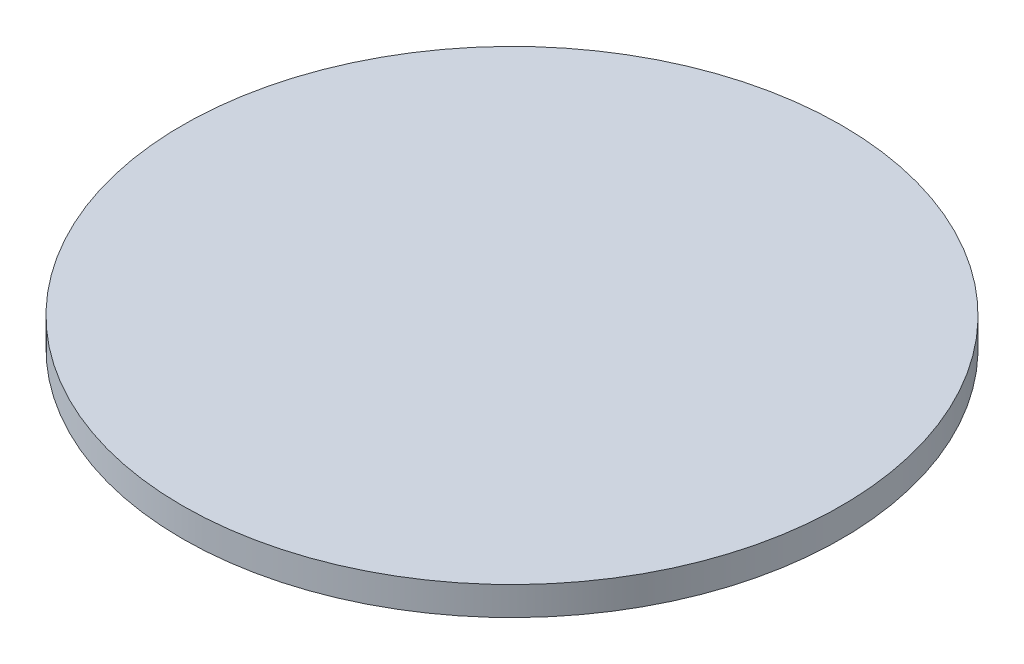
from build123d import *

# Parameters (mm, degrees)
SKETCH1_R           = 36.576
BOSS_EXTRUDE1_DEPTH = 1.5875


with BuildPart() as part:
    # Sketch1 → Boss-Extrude1 (new body, symmetric)
    with BuildSketch(Plane(origin=(0, 0, 0), x_dir=(1, 0, 0), z_dir=(0, 1, 0))):
        Circle(SKETCH1_R)
    extrude(amount=BOSS_EXTRUDE1_DEPTH, both=True)


solid = part.part
